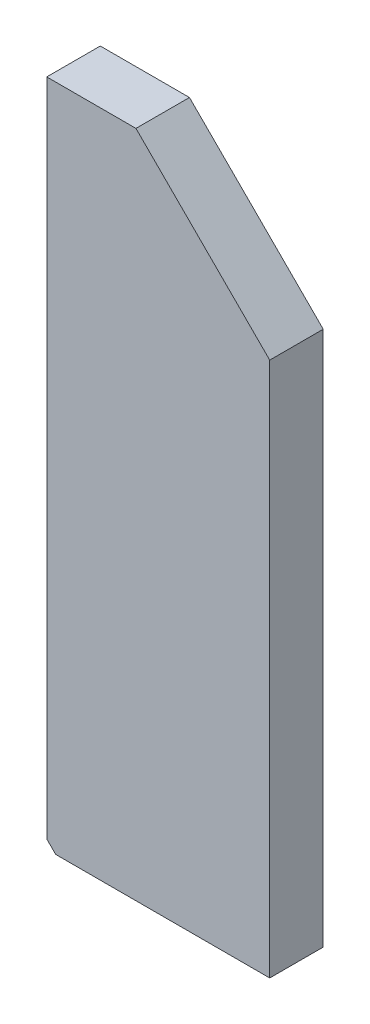
from build123d import *

# Parameters (mm, degrees)
SKETCH1_W             = 50
SKETCH1_H             = 150
BOSS_EXTRUDE1_DEPTH   = 12
M5_TAPPED_HOLE1_D     = 4.2
M5_TAPPED_HOLE1_DEPTH = 10
M5_TAPPED_HOLE1_TIP   = 1.2618073
M5_TAPPED_HOLE2_D     = 4.2
M5_TAPPED_HOLE2_DEPTH = 10
M5_TAPPED_HOLE2_TIP   = 1.2618073
CHAMFER1_SIZE         = 30
CHAMFER2_SIZE         = 2


with BuildPart() as part:
    # Sketch1 → Boss-Extrude1 (new body)
    with BuildSketch(Plane.XY):
        with Locations((-27.5, 38.28125)):
            Rectangle(SKETCH1_W, SKETCH1_H)
    extrude(amount=BOSS_EXTRUDE1_DEPTH)

    # M5 Tapped Hole1
    with Locations(Plane.ZY.offset(52.5)):
        with Locations((6, 98.28125), (6, 43.28125), (6, -11.71875)):
            Hole(M5_TAPPED_HOLE1_D / 2, depth=M5_TAPPED_HOLE1_DEPTH)
            with Locations((0, 0, -(M5_TAPPED_HOLE1_DEPTH + M5_TAPPED_HOLE1_TIP / 2))):  # 118° drill point
                Cone(0, M5_TAPPED_HOLE1_D / 2, M5_TAPPED_HOLE1_TIP, mode=Mode.SUBTRACT)

    # M5 Tapped Hole2
    with Locations(Plane(origin=(0, -36.71875, 0), x_dir=(-1, 0, 0), z_dir=(0, -1, 0))):
        with Locations((46.5, -6), (8.5, -6)):
            Hole(M5_TAPPED_HOLE2_D / 2, depth=M5_TAPPED_HOLE2_DEPTH)
            with Locations((0, 0, -(M5_TAPPED_HOLE2_DEPTH + M5_TAPPED_HOLE2_TIP / 2))):  # 118° drill point
                Cone(0, M5_TAPPED_HOLE2_D / 2, M5_TAPPED_HOLE2_TIP, mode=Mode.SUBTRACT)

    # Chamfer1
    chamfer1_edges = [part.edges().sort_by_distance(p)[0] for p in [
        (-2.5, 113.28125, 6),
    ]]
    chamfer(chamfer1_edges, length=CHAMFER1_SIZE)

    # Chamfer2
    chamfer2_edges = [part.edges().sort_by_distance(p)[0] for p in [
        (-52.5, -36.71875, 6),
    ]]
    chamfer(chamfer2_edges, length=CHAMFER2_SIZE)


solid = part.part
